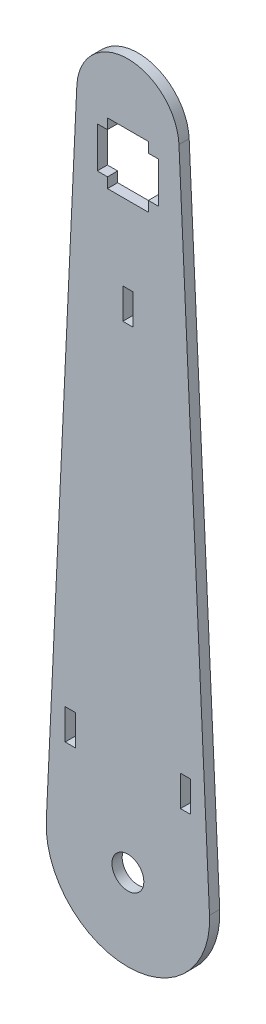
from build123d import *

# Parameters (mm, degrees)
SKETCH1_R           = 4.953
SKETCH1_W           = 3.175
SKETCH1_H           = 9.525
BOSS_EXTRUDE1_DEPTH = 3.175


with BuildPart() as part:
    # Sketch1 → Boss-Extrude1 (new body)
    with BuildSketch(Plane.XY):
        with BuildLine():
            Line((-25.372181386, 1.188449288), (-15.875, 203.943595206))
            ThreePointArc((-15.875, 203.943595206), (0, 219.092405697), (15.875, 203.943595206))
            Line((15.875, 203.943595206), (25.372181386, 1.188449288))
            ThreePointArc((25.372181386, 1.188449288), (0, -25.4), (-25.372181386, 1.188449288))
        make_face()
        Circle(SKETCH1_R, mode=Mode.SUBTRACT)
        Polygon((-6.35, 200.025), (6.35, 200.025), (6.35, 196.85), (9.525, 196.85), (9.525, 184.15), (6.35, 184.15), (6.35, 180.975), (-6.35, 180.975), (-6.35, 184.15), (-9.525, 184.15), (-9.525, 196.85), (-6.35, 196.85), align=None, mode=Mode.SUBTRACT)
        with Locations((-17.9197, 30.1625)):
            Rectangle(SKETCH1_W, SKETCH1_H, mode=Mode.SUBTRACT)
        with Locations((0, 152.4)):
            Rectangle(SKETCH1_W, SKETCH1_H, mode=Mode.SUBTRACT)
        with Locations((17.9197, 30.1625)):
            Rectangle(SKETCH1_W, SKETCH1_H, mode=Mode.SUBTRACT)
    extrude(amount=BOSS_EXTRUDE1_DEPTH)


solid = part.part
